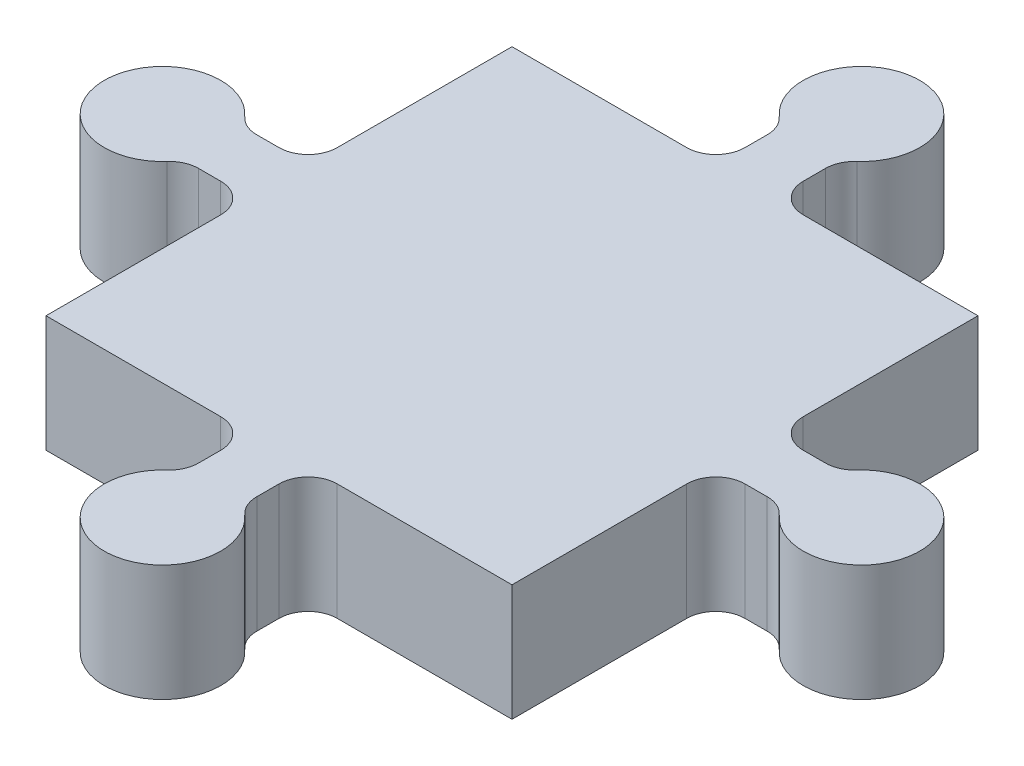
from build123d import *

# Parameters (mm, degrees)
SKETCH1_W           = 8
SKETCH1_H           = 8
BOSS_EXTRUDE1_DEPTH = 2
FILLET2_R           = 0.5


with BuildPart() as part:
    # Sketch1 → Boss-Extrude1 (new body)
    with BuildSketch(Plane(origin=(0, 0, 0), x_dir=(1, 0, 0), z_dir=(0, 1, 0))):
        Rectangle(SKETCH1_W, SKETCH1_H)
        with BuildLine():
            ThreePointArc((-5, 0), (-5.034074174, 0.258819045), (-5.133974596, 0.5))
            Line((-5.133974596, 0.5), (-6, 0.5))
            Line((-6, 0.5), (-6, -0.5))
            Line((-6, -0.5), (-5.133974596, -0.5))
            ThreePointArc((-5.133974596, -0.5), (-5.034074174, -0.258819045), (-5, 0))
        make_face()
        with BuildLine():
            Line((-6, 0.5), (-5.133974596, 0.5))
            ThreePointArc((-5.133974596, 0.5), (-7, 0), (-5.133974596, -0.5))
            Line((-5.133974596, -0.5), (-6, -0.5))
            Line((-6, -0.5), (-6, 0.5))
        make_face()
        with BuildLine():
            Line((-4, -0.5), (-4, 0.5))
            Line((-4, 0.5), (-5.133974596, 0.5))
            ThreePointArc((-5.133974596, 0.5), (-5.034074174, 0.258819045), (-5, 0))
            ThreePointArc((-5, 0), (-5.034074174, -0.258819045), (-5.133974596, -0.5))
            Line((-5.133974596, -0.5), (-4, -0.5))
        make_face()
        with BuildLine():
            Line((0, 5), (0, 4))
            Line((0, 4), (0.5, 4))
            Line((0.5, 4), (0.5, 5.133974596))
            ThreePointArc((0.5, 5.133974596), (0.258819045, 5.034074174), (0, 5))
        make_face()
        with BuildLine():
            Line((-0.5, 5.133974596), (-0.5, 4))
            Line((-0.5, 4), (0, 4))
            Line((0, 4), (0, 5))
            ThreePointArc((0, 5), (-0.258819045, 5.034074174), (-0.5, 5.133974596))
        make_face()
        with BuildLine():
            Line((-0.5, 6), (-0.5, 5.133974596))
            ThreePointArc((-0.5, 5.133974596), (-0.258819045, 5.034074174), (0, 5))
            Line((0, 5), (0, 6))
            Line((0, 6), (-0.5, 6))
        make_face()
        with BuildLine():
            Line((0, 6), (0, 5))
            ThreePointArc((0, 5), (0.258819045, 5.034074174), (0.5, 5.133974596))
            Line((0.5, 5.133974596), (0.5, 6))
            Line((0.5, 6), (0, 6))
        make_face()
        with BuildLine():
            ThreePointArc((1, 6), (-0.5, 6.866025404), (-0.5, 5.133974596))
            Line((-0.5, 5.133974596), (-0.5, 6))
            Line((-0.5, 6), (0, 6))
            Line((0, 6), (0.5, 6))
            Line((0.5, 6), (0.5, 5.133974596))
            ThreePointArc((0.5, 5.133974596), (0.866025404, 5.5), (1, 6))
        make_face()
        with BuildLine():
            ThreePointArc((7, 0), (6.258819045, 0.965925826), (5.133974596, 0.5))
            Line((5.133974596, 0.5), (6, 0.5))
            Line((6, 0.5), (6, -0.5))
            Line((6, -0.5), (5.133974596, -0.5))
            ThreePointArc((5.133974596, -0.5), (6.258819045, -0.965925826), (7, 0))
        make_face()
        with BuildLine():
            Line((6, 0.5), (5.133974596, 0.5))
            ThreePointArc((5.133974596, 0.5), (5, 0), (5.133974596, -0.5))
            Line((5.133974596, -0.5), (6, -0.5))
            Line((6, -0.5), (6, 0.5))
        make_face()
        with BuildLine():
            ThreePointArc((0.5, -5.133974596), (0, -5), (-0.5, -5.133974596))
            Line((-0.5, -5.133974596), (-0.5, -6))
            Line((-0.5, -6), (0.5, -6))
            Line((0.5, -6), (0.5, -5.133974596))
        make_face()
        with BuildLine():
            Line((-0.5, -6), (-0.5, -5.133974596))
            ThreePointArc((-0.5, -5.133974596), (-0.5, -6.866025404), (1, -6))
            ThreePointArc((1, -6), (0.866025404, -5.5), (0.5, -5.133974596))
            Line((0.5, -5.133974596), (0.5, -6))
            Line((0.5, -6), (-0.5, -6))
        make_face()
        with BuildLine():
            Line((0.5, -4), (-0.5, -4))
            Line((-0.5, -4), (-0.5, -5.133974596))
            ThreePointArc((-0.5, -5.133974596), (0, -5), (0.5, -5.133974596))
            Line((0.5, -5.133974596), (0.5, -4))
        make_face()
        with BuildLine():
            Line((5.133974596, 0.5), (4, 0.5))
            Line((4, 0.5), (4, -0.5))
            Line((4, -0.5), (5.133974596, -0.5))
            ThreePointArc((5.133974596, -0.5), (5, 0), (5.133974596, 0.5))
        make_face()
    extrude(amount=BOSS_EXTRUDE1_DEPTH)

    # Fillet2
    fillet2_edges = [part.edges().sort_by_distance(p)[0] for p in [
        (0.5, 1, -4),
        (4, 1, -0.5),
        (5.133974596, 1, -0.5),
        (5.133974596, 1, 0.5),
        (4, 1, 0.5),
        (0.5, 1, 4),
        (0.5, 1, 5.133974596),
        (-0.5, 1, 5.133974596),
        (-0.5, 1, 4),
        (-4, 1, 0.5),
        (-5.133974596, 1, 0.5),
        (-5.133974596, 1, -0.5),
        (-4, 1, -0.5),
        (-0.5, 1, -4),
        (-0.5, 1, -5.133974596),
        (0.5, 1, -5.133974596),
    ]]
    fillet(fillet2_edges, radius=FILLET2_R)


solid = part.part
